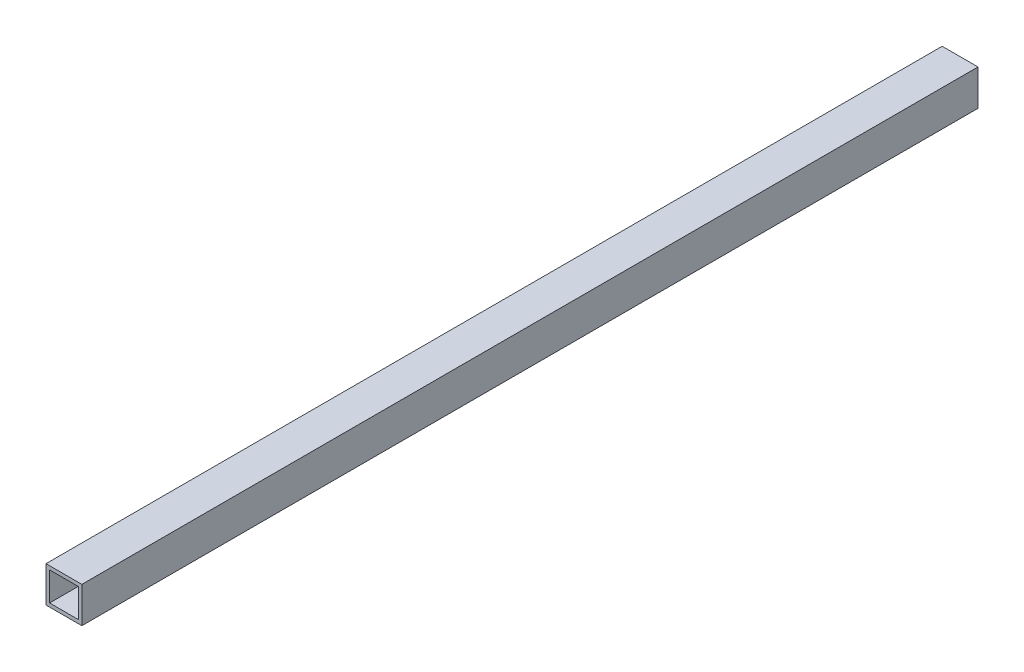
from build123d import *

# Parameters (mm, degrees)
SKETCH1_W   = 40
SKETCH1_H   = 40
SKETCH1_W_2 = 32
SKETCH1_H_2 = 32


with BuildPart() as part:
    # Sweep1: sweep along a curve in space
    with BuildLine() as sweep1_path:
        add(Edge.make_bspline(
            [(0, 0, -500), (0, 0, 500)],
            knots=[0, 0, 1, 1], degree=1))
    # Sketch1 → Sweep1 (sweep)
    with BuildSketch(Plane.XY):
        Rectangle(SKETCH1_W, SKETCH1_H)
        Rectangle(SKETCH1_W_2, SKETCH1_H_2, mode=Mode.SUBTRACT)
    sweep(path=sweep1_path.line)


solid = part.part
